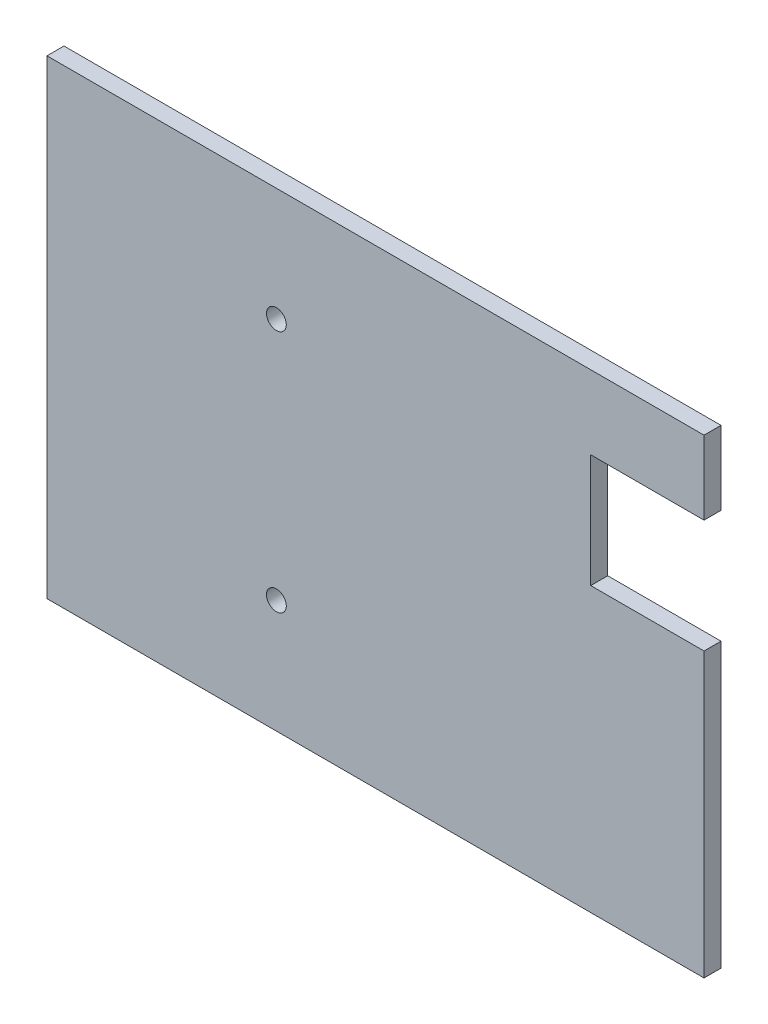
from build123d import *

# Parameters (mm, degrees)
SKETCH1_W           = 116
SKETCH1_H           = 83
SKETCH1_W_2         = 70
SKETCH1_H_2         = 77
SKETCH1_W_3         = 35
BOSS_EXTRUDE1_DEPTH = 3
SKETCH2_W           = 70
SKETCH2_H           = 77
SKETCH2_W_2         = 35
BOSS_EXTRUDE2_DEPTH = 3
SKETCH6_R           = 1.75
CUT_EXTRUDE4_DEPTH  = 30
SKETCH8_W           = 20
SKETCH8_H           = 20
CUT_EXTRUDE6_DEPTH  = 10


with BuildPart() as part:
    # Sketch1 → Boss-Extrude1 (new body)
    with BuildSketch(Plane.XY):
        with Locations((-58, 41.5)):
            Rectangle(SKETCH1_W, SKETCH1_H)
        with Locations((-38, 41.5)):
            Rectangle(SKETCH1_W_2, SKETCH1_H_2, mode=Mode.SUBTRACT)
        with Locations((-95.5, 41.5)):
            Rectangle(SKETCH1_W_3, SKETCH1_H_2, mode=Mode.SUBTRACT)
    extrude(amount=BOSS_EXTRUDE1_DEPTH)

    # Sketch2 → Boss-Extrude2 (add)
    with BuildSketch(Plane(origin=(0, 0, 0), x_dir=(-1, 0, 0), z_dir=(0, 0, -1))):
        with Locations((38, 41.5)):
            Rectangle(SKETCH2_W, SKETCH2_H)
        with Locations((95.5, 41.5)):
            Rectangle(SKETCH2_W_2, SKETCH2_H)
    extrude(amount=-BOSS_EXTRUDE2_DEPTH)

    # Sketch6 → Cut-Extrude4 (cut)
    with BuildSketch(Plane.XY.offset(3)):
        with Locations((-75.5, 63)):
            Circle(SKETCH6_R)
        with Locations((-75.5, 20)):
            Circle(SKETCH6_R)
    extrude(amount=-CUT_EXTRUDE4_DEPTH, mode=Mode.SUBTRACT)

    # Sketch8 → Cut-Extrude6 (cut)
    with BuildSketch(Plane.XY.offset(3)):
        with Locations((-10, 60)):
            Rectangle(SKETCH8_W, SKETCH8_H)
    extrude(amount=-CUT_EXTRUDE6_DEPTH, mode=Mode.SUBTRACT)


solid = part.part
